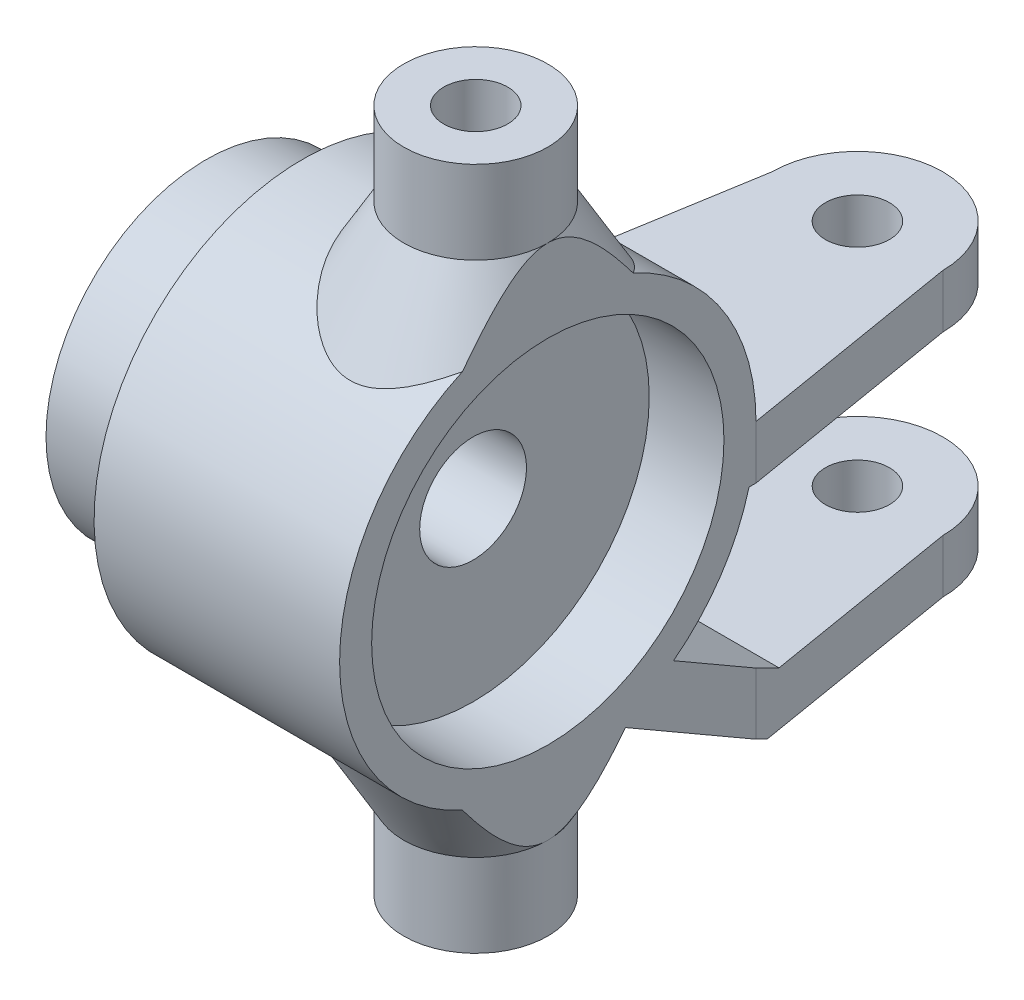
from build123d import *

# Parameters (mm, degrees)
SKETCH3_W           = 7.302665
SKETCH3_H           = 36.305572
FACE_CUT_DEPTH      = 10
LINK_ARMS_REACH     = 26.639
ROUNDED_LINKS_REACH = 32.365
SKETCH6_R           = 4
TRIM_1_REACH        = 35.167
SKETCH7_R           = 1.5
SKETCH8_W           = 8
SKETCH8_H           = 8.25
TRIM_2_DEPTH        = 15


with BuildPart() as part:
    # Sketch1 → Base Cylinder (revolve)
    with BuildSketch(Plane.XY, mode=Mode.PRIVATE) as base_cylinder_sk:
        with BuildLine():
            Line((-16, 2.5), (-16, 7.5))
            Line((-16, 7.5), (-12.5, 7.5))
            ThreePointArc((-12.5, 7.5), (-11.792893, 7.792893), (-11.5, 8.5))
            Line((-11.5, 8.5), (-11.5, 9.75))
            Line((-11.5, 9.75), (0, 9.75))
            Line((0, 9.75), (0, 8.25))
            Line((0, 8.25), (-3.5, 8.25))
            Line((-3.5, 8.25), (-3.5, 2.5))
            Line((-3.5, 2.5), (-16, 2.5))
        make_face()
    revolve(base_cylinder_sk.sketch.rotate(Axis((-29.02439, 0, 0), (1, 0, 0)), 90), axis=Axis((-29.02439, 0, 0), (1, 0, 0)))

    # Sketch2 → Suspension attachments (revolve)
    with BuildSketch(Plane(origin=(-3.375, 0, 0), x_dir=(0, 0, -1), z_dir=(1, 0, 0))):
        with BuildLine():
            Line((-3.375, 16), (-1.5, 16))
            Line((-1.5, 16), (-1.5, 9.633924))
            ThreePointArc((-1.5, 9.633924), (-3.80208, 8.978123), (-5.875, 7.781187))
            Line((-5.875, 7.781187), (-3.375, 12.111314))
            Line((-3.375, 12.111314), (-3.375, 16))
        make_face()
    suspension_attachments = revolve(axis=Axis((-3.375, 16.888615, 0), (0, -1, 0)))

    # Mirror1: Suspension attachments across plane
    add(suspension_attachments.mirror(Plane.ZX))

    # Sketch3 → Face Cut (cut, symmetric)
    with BuildSketch(Plane.XY):
        with Locations((3.651332, -0.216492)):
            Rectangle(SKETCH3_W, SKETCH3_H)
    extrude(amount=FACE_CUT_DEPTH, both=True, mode=Mode.SUBTRACT)

    # Link Arms: up to this face of the body (flat: up to its plane)
    link_arms_end = Plane(part.part.faces().sort_by_distance((-11.5, 0, -8.775772))[0])
    # Sketch5 → Link Arms (add, up to the picked face)
    with BuildSketch(Plane(origin=(0, 0, 0), x_dir=(0, 0, -1), z_dir=(1, 0, 0)), mode=Mode.PRIVATE) as link_arms_sk1:
        with BuildLine():
            Line((9.75, 0), (20.25, 0))
            Line((20.25, 0), (20.25, -2.5))
            Line((20.25, -2.5), (9.424038, -2.5))
            ThreePointArc((9.424038, -2.5), (9.668166, -1.26058), (9.75, 0))
        make_face()
    link_arms_tool1 = split(extrude(link_arms_sk1.sketch, amount=-LINK_ARMS_REACH, mode=Mode.PRIVATE), bisect_by=link_arms_end, keep=Keep.BOTH, mode=Mode.PRIVATE)
    # Sketch5 → Link Arms (add, up to the picked face)
    with BuildSketch(Plane(origin=(0, 0, 0), x_dir=(0, 0, -1), z_dir=(1, 0, 0)), mode=Mode.PRIVATE) as link_arms_sk2:
        with BuildLine():
            Line((5.887009, -7.772106), (11.044873, -10.75))
            Line((11.044873, -10.75), (20.25, -10.75))
            Line((20.25, -10.75), (20.25, -13.25))
            Line((20.25, -13.25), (10.375, -13.25))
            Line((10.375, -13.25), (3.309929, -9.17098))
            ThreePointArc((3.309929, -9.17098), (4.651358, -8.568977), (5.887009, -7.772106))
        make_face()
    link_arms_tool2 = split(extrude(link_arms_sk2.sketch, amount=-LINK_ARMS_REACH, mode=Mode.PRIVATE), bisect_by=link_arms_end, keep=Keep.BOTH, mode=Mode.PRIVATE)
    add(link_arms_tool1.solids().sort_by(Axis((0, -1.25638, -14.945599), (-1, 0, 0)))[0])
    add(link_arms_tool2.solids().sort_by(Axis((0, -11.294384, -12.172928), (-1, 0, 0)))[0])

    # Rounded Links: up to this face of the body (flat: up to its plane)
    rounded_links_end = Plane(part.part.faces().sort_by_distance((-5.75, -13.25, -15.3125))[0])
    # Sketch6 → Rounded Links (add, up to the picked face)
    with BuildSketch(Plane(origin=(0, 0, 0), x_dir=(1, 0, 0), z_dir=(0, 1, 0)), mode=Mode.PRIVATE) as rounded_links_sk1:
        with Locations(Location((-5.75, 20.25, 0), (0, 0, 180))):
            Circle(SKETCH6_R)
    rounded_links_tool1 = split(extrude(rounded_links_sk1.sketch, amount=-ROUNDED_LINKS_REACH, mode=Mode.PRIVATE), bisect_by=rounded_links_end, keep=Keep.BOTH, mode=Mode.PRIVATE)
    add(rounded_links_tool1.solids().sort_by(Axis((-5.75, 0, -20.25), (0, -1, 0)))[0])

    # Trim 1: up to this face of the body (flat: up to its plane)
    trim_1_end = Plane(part.part.faces().sort_by_distance((-5.75, -13.25, -16.514845))[0])
    # Sketch7 → Trim 1 (cut, up to the picked face)
    with BuildSketch(Plane(origin=(0, 0, 0), x_dir=(1, 0, 0), z_dir=(0, 1, 0)), mode=Mode.PRIVATE) as trim_1_sk1:
        with Locations(Location((-5.75, 20.25, 0), (0, 0, 270))):
            Circle(SKETCH7_R)
    trim_1_tool1 = split(extrude(trim_1_sk1.sketch, amount=-TRIM_1_REACH, mode=Mode.PRIVATE), bisect_by=trim_1_end, keep=Keep.BOTH, mode=Mode.PRIVATE)
    # Sketch7 → Trim 1 (cut, up to the picked face)
    with BuildSketch(Plane(origin=(0, 0, 0), x_dir=(1, 0, 0), z_dir=(0, 1, 0)), mode=Mode.PRIVATE) as trim_1_sk2:
        Polygon((-9.75, 20.25), (-11.5, 9.75), (-11.5, 20.25), align=None)
    trim_1_tool2 = split(extrude(trim_1_sk2.sketch, amount=-TRIM_1_REACH, mode=Mode.PRIVATE), bisect_by=trim_1_end, keep=Keep.BOTH, mode=Mode.PRIVATE)
    # Sketch7 → Trim 1 (cut, up to the picked face)
    with BuildSketch(Plane(origin=(0, 0, 0), x_dir=(1, 0, 0), z_dir=(0, 1, 0)), mode=Mode.PRIVATE) as trim_1_sk3:
        Polygon((-1.75, 20.25), (0, 9.75), (0, 20.25), align=None)
    trim_1_tool3 = split(extrude(trim_1_sk3.sketch, amount=-TRIM_1_REACH, mode=Mode.PRIVATE), bisect_by=trim_1_end, keep=Keep.BOTH, mode=Mode.PRIVATE)
    add(trim_1_tool1.solids().sort_by(Axis((-5.75, 0, -20.25), (0, -1, 0)))[0], mode=Mode.SUBTRACT)
    add(trim_1_tool2.solids().sort_by(Axis((-10.916667, 0, -16.75), (0, -1, 0)))[0], mode=Mode.SUBTRACT)
    add(trim_1_tool3.solids().sort_by(Axis((-0.583333, 0, -16.75), (0, -1, 0)))[0], mode=Mode.SUBTRACT)

    # Sketch8 → Trim 2 (cut, symmetric)
    with BuildSketch(Plane(origin=(1.581081, 0, -0.263514), x_dir=(-0.1643989873053571, 0, -0.9863939238321439), z_dir=(0.9863939238321439, 0, -0.1643989873053571))):
        with Locations((20.919771, -6.625)):
            Rectangle(SKETCH8_W, SKETCH8_H)
    extrude(amount=TRIM_2_DEPTH, both=True, mode=Mode.SUBTRACT)


solid = part.part
